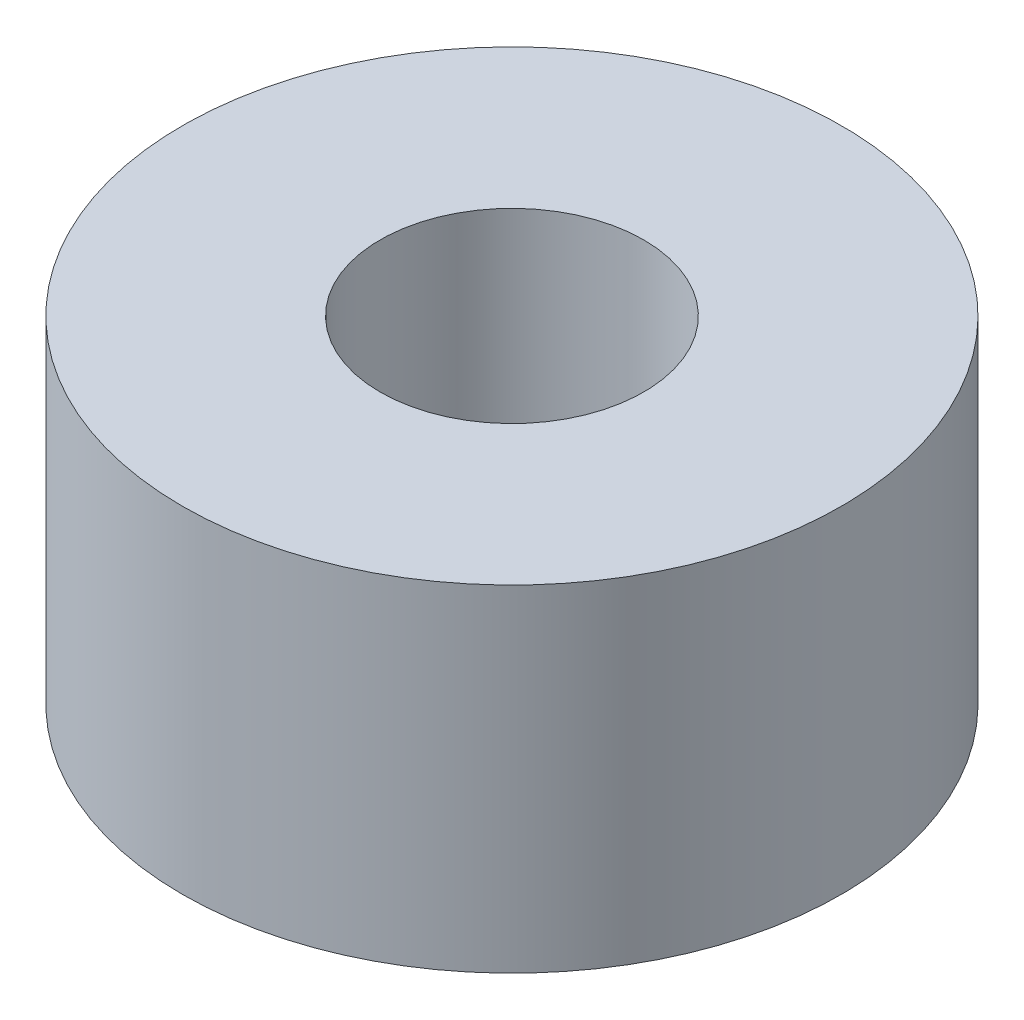
from build123d import *

# Parameters (mm, degrees)
SKETCH2_R           = 5
SKETCH2_R_2         = 2
BOSS_EXTRUDE1_DEPTH = 2.55


with BuildPart() as part:
    # Sketch2 → Boss-Extrude1 (new body, symmetric)
    with BuildSketch(Plane(origin=(0, 0, 0), x_dir=(1, 0, 0), z_dir=(0, 1, 0))):
        Circle(SKETCH2_R)
        Circle(SKETCH2_R_2, mode=Mode.SUBTRACT)
    extrude(amount=BOSS_EXTRUDE1_DEPTH, both=True)


solid = part.part
